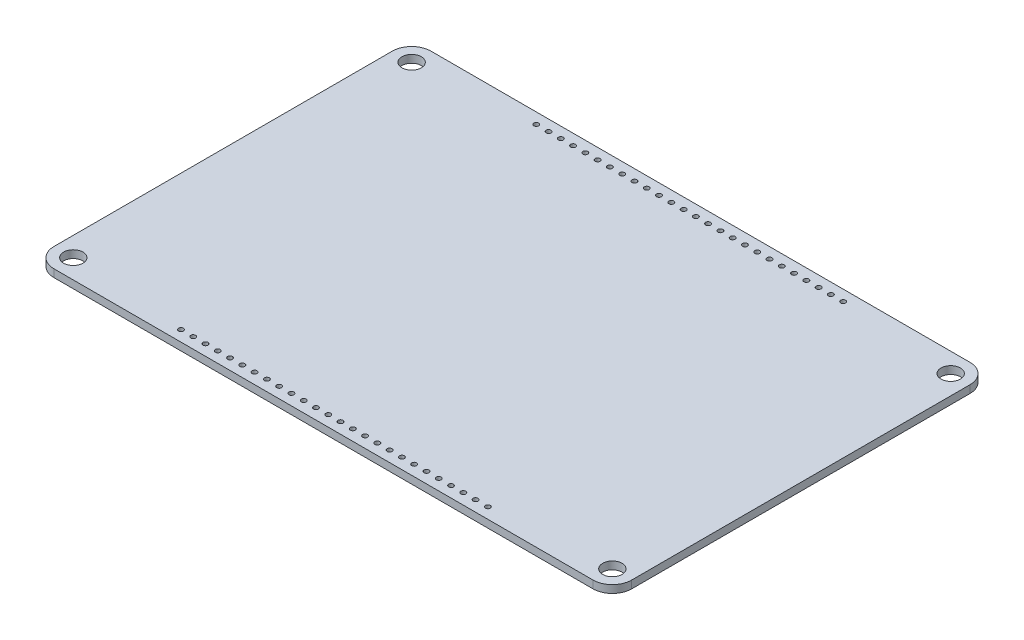
from build123d import *

# Parameters (mm, degrees)
SKETCH1_W           = 119.5324
SKETCH1_H           = 78.0034
BOSS_EXTRUDE1_DEPTH = 1.5875
CUT_EXTRUDE1_REACH  = 73.384
SKETCH2_R           = 2
CUT_EXTRUDE2_REACH  = 73.384
SKETCH3_R           = 0.508
CUT_EXTRUDE4_REACH  = 73.384
LPATTERN1_COUNT     = 26
LPATTERN1_PITCH     = 2.54


with BuildPart() as part:
    # Sketch1 → Boss-Extrude1 (new body)
    with BuildSketch(Plane(origin=(0, 0, 0), x_dir=(1, 0, 0), z_dir=(0, 1, 0))):
        Rectangle(SKETCH1_W, SKETCH1_H)
    extrude(amount=BOSS_EXTRUDE1_DEPTH)

    # Sketch2 → Cut-Extrude1 (cut, up to next)
    with BuildSketch(Plane(origin=(0, 1.5875, 0), x_dir=(1, 0, 0), z_dir=(0, 1, 0)), mode=Mode.PRIVATE) as cut_extrude1_sk1:
        with Locations((-55.7657, 35.0012)):
            Circle(SKETCH2_R)
    cut_extrude1_tool1 = extrude(cut_extrude1_sk1.sketch, amount=-CUT_EXTRUDE1_REACH, mode=Mode.PRIVATE) & part.part
    # Sketch2 → Cut-Extrude1 (cut, up to next)
    with BuildSketch(Plane(origin=(0, 1.5875, 0), x_dir=(1, 0, 0), z_dir=(0, 1, 0)), mode=Mode.PRIVATE) as cut_extrude1_sk2:
        with Locations((-55.7657, -35.0012)):
            Circle(SKETCH2_R)
    cut_extrude1_tool2 = extrude(cut_extrude1_sk2.sketch, amount=-CUT_EXTRUDE1_REACH, mode=Mode.PRIVATE) & part.part
    # Sketch2 → Cut-Extrude1 (cut, up to next)
    with BuildSketch(Plane(origin=(0, 1.5875, 0), x_dir=(1, 0, 0), z_dir=(0, 1, 0)), mode=Mode.PRIVATE) as cut_extrude1_sk3:
        with Locations((55.7657, 35.0012)):
            Circle(SKETCH2_R)
    cut_extrude1_tool3 = extrude(cut_extrude1_sk3.sketch, amount=-CUT_EXTRUDE1_REACH, mode=Mode.PRIVATE) & part.part
    # Sketch2 → Cut-Extrude1 (cut, up to next)
    with BuildSketch(Plane(origin=(0, 1.5875, 0), x_dir=(1, 0, 0), z_dir=(0, 1, 0)), mode=Mode.PRIVATE) as cut_extrude1_sk4:
        with Locations((55.7657, -35.0012)):
            Circle(SKETCH2_R)
    cut_extrude1_tool4 = extrude(cut_extrude1_sk4.sketch, amount=-CUT_EXTRUDE1_REACH, mode=Mode.PRIVATE) & part.part
    add(cut_extrude1_tool1.solids().sort_by_distance((-55.7657, 1.5875, -35.0012))[0], mode=Mode.SUBTRACT)
    add(cut_extrude1_tool2.solids().sort_by_distance((-55.7657, 1.5875, 35.0012))[0], mode=Mode.SUBTRACT)
    add(cut_extrude1_tool3.solids().sort_by_distance((55.7657, 1.5875, -35.0012))[0], mode=Mode.SUBTRACT)
    add(cut_extrude1_tool4.solids().sort_by_distance((55.7657, 1.5875, 35.0012))[0], mode=Mode.SUBTRACT)

    # Sketch3 → Cut-Extrude2 (cut, up to next)
    with BuildSketch(Plane(origin=(0, 1.5875, 0), x_dir=(1, 0, 0), z_dir=(0, 1, 0)), mode=Mode.PRIVATE) as cut_extrude2_sk1:
        with Locations((-31.7373, 36.758)):
            Circle(SKETCH3_R)
    cut_extrude2_tool1 = extrude(cut_extrude2_sk1.sketch, amount=-CUT_EXTRUDE2_REACH, mode=Mode.PRIVATE) & part.part
    # Sketch3 → Cut-Extrude2 (cut, up to next)
    with BuildSketch(Plane(origin=(0, 1.5875, 0), x_dir=(1, 0, 0), z_dir=(0, 1, 0)), mode=Mode.PRIVATE) as cut_extrude2_sk2:
        with Locations((-31.7373, -36.758)):
            Circle(SKETCH3_R)
    cut_extrude2_tool2 = extrude(cut_extrude2_sk2.sketch, amount=-CUT_EXTRUDE2_REACH, mode=Mode.PRIVATE) & part.part
    cut_extrude2_1 = cut_extrude2_tool1.solids().sort_by_distance((-31.7373, 1.5875, -36.758))[0]
    add(cut_extrude2_1, mode=Mode.SUBTRACT)
    cut_extrude2_2 = cut_extrude2_tool2.solids().sort_by_distance((-31.7373, 1.5875, 36.758))[0]
    add(cut_extrude2_2, mode=Mode.SUBTRACT)
    cut_extrude2 = cut_extrude2_1 + cut_extrude2_2  # Cut-Extrude2 as one shape, for the pattern or mirror that repeats it

    # Sketch11 → Cut-Extrude4 (cut, up to next)
    with BuildSketch(Plane(origin=(0, 1.5875, 0), x_dir=(1, 0, 0), z_dir=(0, 1, 0)), mode=Mode.PRIVATE) as cut_extrude4_sk1:
        with BuildLine():
            Line((-59.7662, 35.0012), (-59.7662, 39.0017))
            Line((-59.7662, 39.0017), (-55.7657, 39.0017))
            ThreePointArc((-55.7657, 39.0017), (-58.594480678, 37.829980678), (-59.7662, 35.0012))
        make_face()
    cut_extrude4_tool1 = extrude(cut_extrude4_sk1.sketch, amount=-CUT_EXTRUDE4_REACH, mode=Mode.PRIVATE) & part.part
    # Sketch11 → Cut-Extrude4 (cut, up to next)
    with BuildSketch(Plane(origin=(0, 1.5875, 0), x_dir=(1, 0, 0), z_dir=(0, 1, 0)), mode=Mode.PRIVATE) as cut_extrude4_sk2:
        with BuildLine():
            Line((-59.7662, -39.0017), (-55.7657, -39.0017))
            ThreePointArc((-55.7657, -39.0017), (-58.594480678, -37.829980678), (-59.7662, -35.0012))
            Line((-59.7662, -35.0012), (-59.7662, -39.0017))
        make_face()
    cut_extrude4_tool2 = extrude(cut_extrude4_sk2.sketch, amount=-CUT_EXTRUDE4_REACH, mode=Mode.PRIVATE) & part.part
    # Sketch11 → Cut-Extrude4 (cut, up to next)
    with BuildSketch(Plane(origin=(0, 1.5875, 0), x_dir=(1, 0, 0), z_dir=(0, 1, 0)), mode=Mode.PRIVATE) as cut_extrude4_sk3:
        with BuildLine():
            Line((59.7662, -35.0012), (59.7662, -39.0017))
            Line((59.7662, -39.0017), (55.7657, -39.0017))
            ThreePointArc((55.7657, -39.0017), (58.594480678, -37.829980678), (59.7662, -35.0012))
        make_face()
    cut_extrude4_tool3 = extrude(cut_extrude4_sk3.sketch, amount=-CUT_EXTRUDE4_REACH, mode=Mode.PRIVATE) & part.part
    # Sketch11 → Cut-Extrude4 (cut, up to next)
    with BuildSketch(Plane(origin=(0, 1.5875, 0), x_dir=(1, 0, 0), z_dir=(0, 1, 0)), mode=Mode.PRIVATE) as cut_extrude4_sk4:
        with BuildLine():
            Line((59.7662, 39.0017), (55.7657, 39.0017))
            ThreePointArc((55.7657, 39.0017), (58.594480678, 37.829980678), (59.7662, 35.0012))
            Line((59.7662, 35.0012), (59.7662, 39.0017))
        make_face()
    cut_extrude4_tool4 = extrude(cut_extrude4_sk4.sketch, amount=-CUT_EXTRUDE4_REACH, mode=Mode.PRIVATE) & part.part
    add(cut_extrude4_tool1.solids().sort_by_distance((-58.872617, 1.5875, -38.108117))[0], mode=Mode.SUBTRACT)
    add(cut_extrude4_tool2.solids().sort_by_distance((-58.872617, 1.5875, 38.108117))[0], mode=Mode.SUBTRACT)
    add(cut_extrude4_tool3.solids().sort_by_distance((58.872617, 1.5875, 38.108117))[0], mode=Mode.SUBTRACT)
    add(cut_extrude4_tool4.solids().sort_by_distance((58.872617, 1.5875, -38.108117))[0], mode=Mode.SUBTRACT)

    # LPattern1: Cut-Extrude2 ×26
    with Locations(*[(i * LPATTERN1_PITCH, 0, 0) for i in range(1, LPATTERN1_COUNT)]):
        add(cut_extrude2, mode=Mode.SUBTRACT)


solid = part.part
